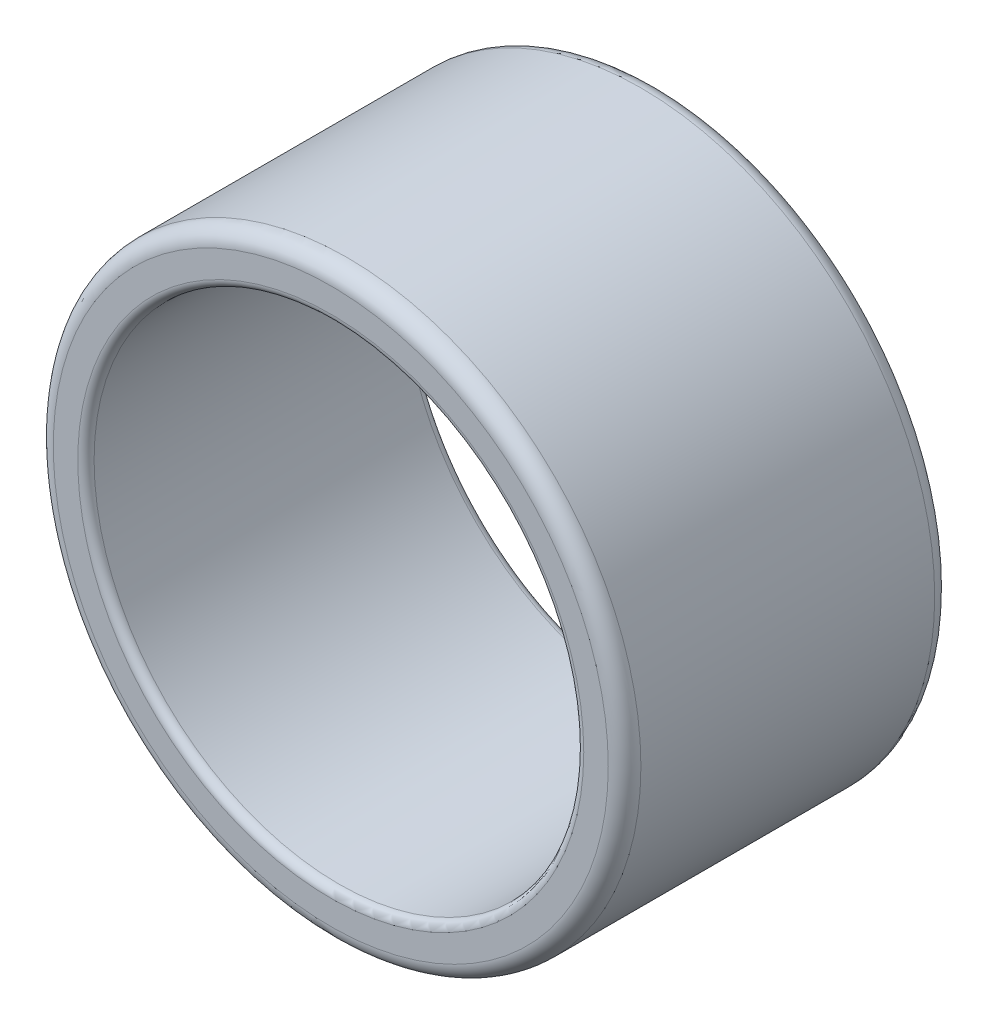
from build123d import *

# Parameters (mm, degrees)
IZIM1_R                     = 180
Y_KSEKLIK_EKSTR_ZYON1_DEPTH = 200
RADYUS2_R                   = 10
IZIM2_R                     = 150
KES_EKSTR_ZYON1_DEPTH       = 200
RADYUS3_R                   = 5


with BuildPart() as part:
    # Çizim1 → Yükseklik-Ekstrüzyon1 (new body)
    with BuildSketch(Plane.XY):
        Circle(IZIM1_R)
    extrude(amount=Y_KSEKLIK_EKSTR_ZYON1_DEPTH)

    # Radyus2
    radyus2_edges = [part.edges().sort_by_distance(p)[0] for p in [
        (-180, 0, 0),
        (-180, 0, 200),
    ]]
    fillet(radyus2_edges, radius=RADYUS2_R)

    # Çizim2 → Kes-Ekstrüzyon1 (cut)
    with BuildSketch(Plane(origin=(0, 0, 0), x_dir=(-1, 0, 0), z_dir=(0, 0, -1))):
        Circle(IZIM2_R)
    extrude(amount=-KES_EKSTR_ZYON1_DEPTH, mode=Mode.SUBTRACT)

    # Radyus3
    radyus3_edges = [part.edges().sort_by_distance(p)[0] for p in [
        (150, 0, 200),
        (150, 0, 0),
    ]]
    fillet(radyus3_edges, radius=RADYUS3_R)


solid = part.part
